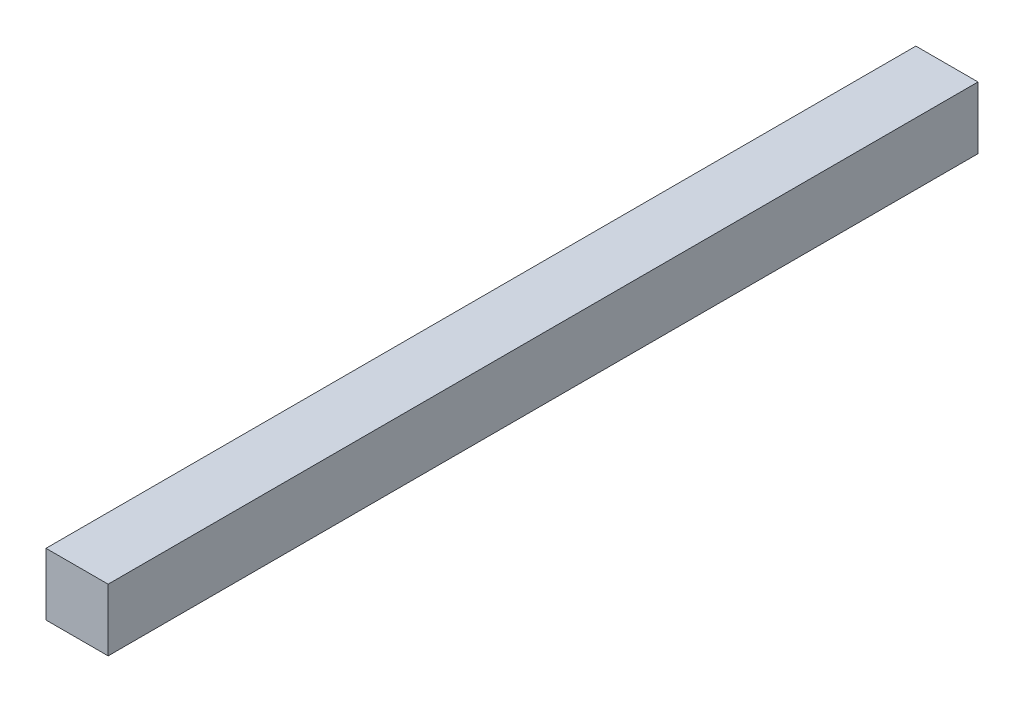
from build123d import *

# Parameters (mm, degrees)
SKETCH1_W           = 10
SKETCH1_H           = 10
BOSS_EXTRUDE1_DEPTH = 140


with BuildPart() as part:
    # Sketch1 → Boss-Extrude1 (new body)
    with BuildSketch(Plane.XY):
        with Locations((-99.49577739, 29.161428773)):
            Rectangle(SKETCH1_W, SKETCH1_H)
    extrude(amount=BOSS_EXTRUDE1_DEPTH)


solid = part.part
